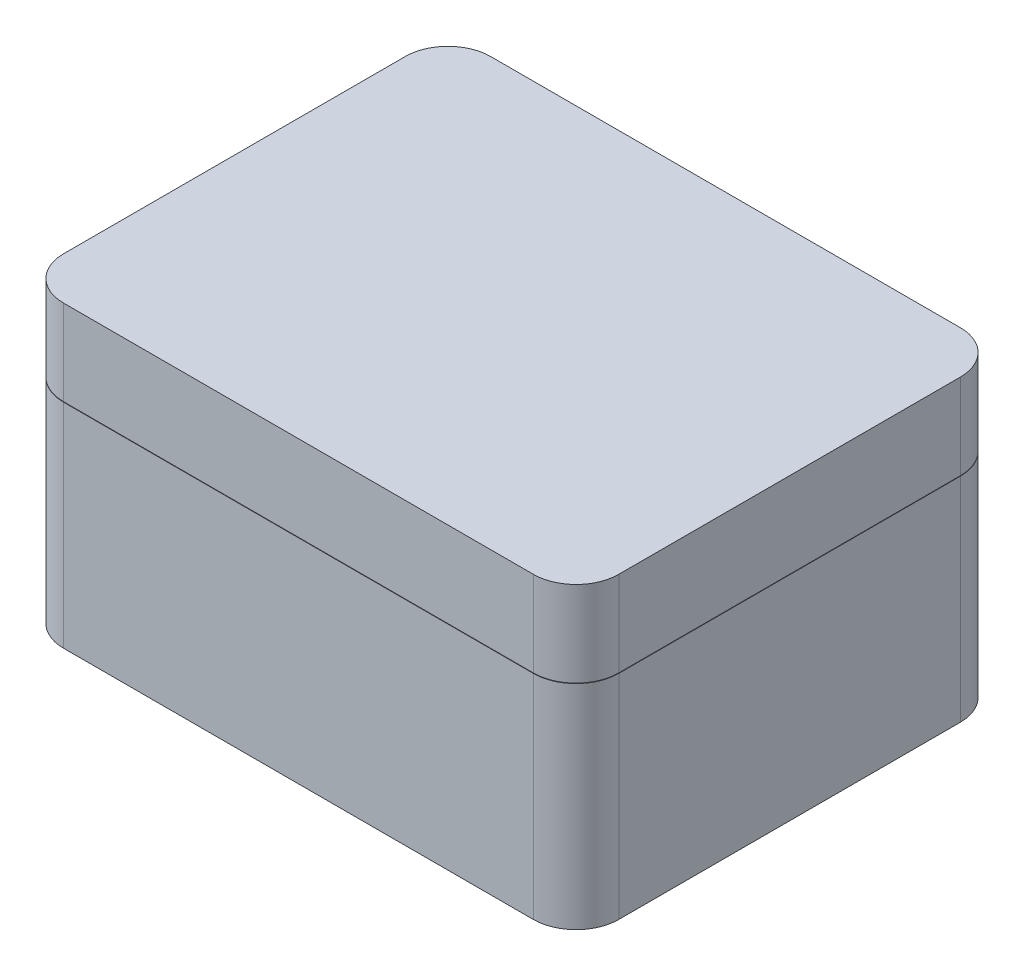
from build123d import *

# Parameters (mm, degrees)
SKETCH1_W           = 65
SKETCH1_H           = 50
BOSS_EXTRUDE1_DEPTH = 35
FILLET2_R           = 5
SHELL3_T            = 2
SKETCH5_W           = 50
SKETCH5_H           = 0.05
CUT_EXTRUDE1_DEPTH  = 66
CUT_EXTRUDE2_REACH  = 37
SKETCH6_R           = 2


with BuildPart() as part:
    # Sketch1 → Boss-Extrude1 (new body)
    with BuildSketch(Plane(origin=(0, 0, 0), x_dir=(1, 0, 0), z_dir=(0, 1, 0))):
        Rectangle(SKETCH1_W, SKETCH1_H)
    extrude(amount=BOSS_EXTRUDE1_DEPTH)

    # Fillet2
    fillet2_edges = [part.edges().sort_by_distance(p)[0] for p in [
        (32.5, 17.5, 25),
        (-32.5, 17.5, 25),
        (-32.5, 17.5, -25),
        (32.5, 17.5, -25),
    ]]
    fillet(fillet2_edges, radius=FILLET2_R)

    # Shell3 (no face opened: a closed hollow body)
    add(offset(amount=-SHELL3_T, mode=Mode.PRIVATE), mode=Mode.SUBTRACT)

    # Sketch5 → Cut-Extrude1 (cut, through all)
    with BuildSketch(Plane(origin=(32.5, 0, 0), x_dir=(0, 0, -1), z_dir=(1, 0, 0))):
        with Locations((0, 24.975)):
            Rectangle(SKETCH5_W, SKETCH5_H)
    extrude(amount=-CUT_EXTRUDE1_DEPTH, mode=Mode.SUBTRACT)

    # Sketch6 → Cut-Extrude2 (cut, up to next)
    with BuildSketch(Plane.XZ, mode=Mode.PRIVATE) as cut_extrude2_sk1:
        with Locations((-27.25, 19.75)):
            Circle(SKETCH6_R)
    cut_extrude2_tool1 = extrude(cut_extrude2_sk1.sketch, amount=-CUT_EXTRUDE2_REACH, mode=Mode.PRIVATE) & part.part
    add(cut_extrude2_tool1.solids().sort_by_distance((-27.25, 0, 19.75))[0], mode=Mode.SUBTRACT)
    # Sketch6 → Cut-Extrude2 (cut, up to next)
    with BuildSketch(Plane.XZ, mode=Mode.PRIVATE) as cut_extrude2_sk2:
        with Locations((25.25, -17.75)):
            Circle(SKETCH6_R)
    cut_extrude2_tool2 = extrude(cut_extrude2_sk2.sketch, amount=-CUT_EXTRUDE2_REACH, mode=Mode.PRIVATE) & part.part
    add(cut_extrude2_tool2.solids().sort_by_distance((25.25, 0, -17.75))[0], mode=Mode.SUBTRACT)


solid = part.part
